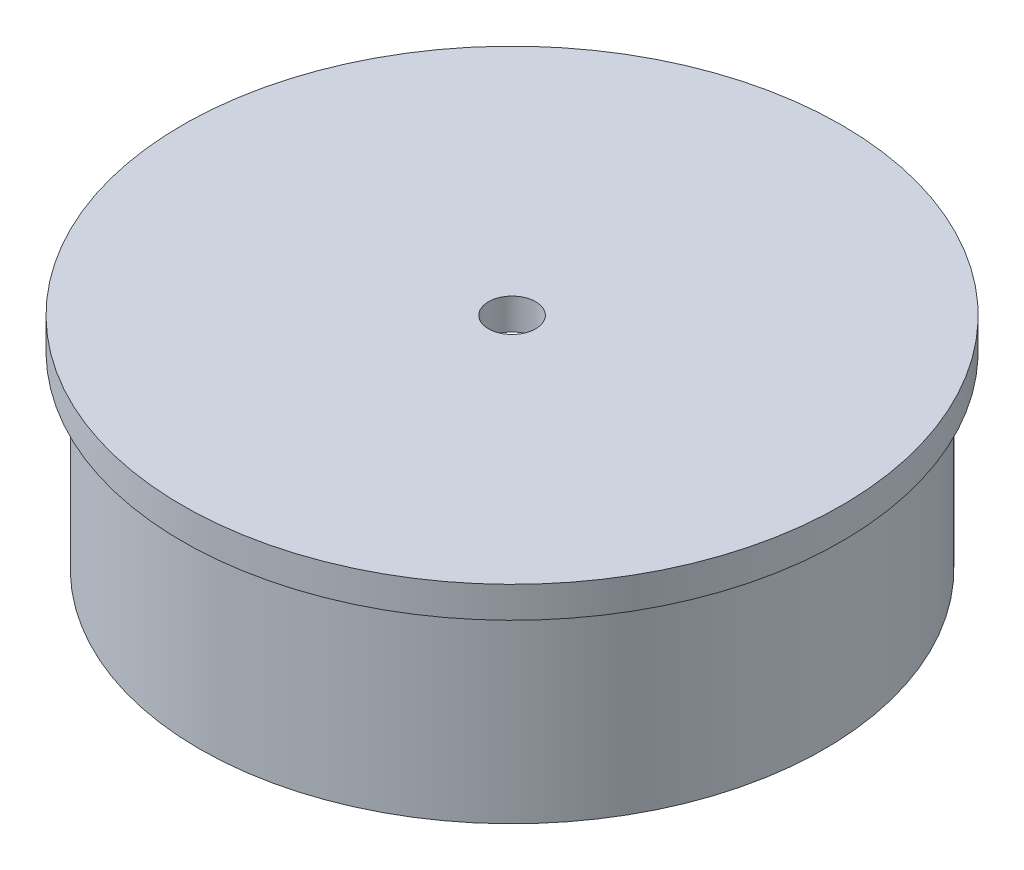
from build123d import *

# Parameters (mm, degrees)
SKETCH3_R = 2.38125
FILLET1_R = 1.27


with BuildPart() as part:
    # Sketch1 → Revolve1 (revolve)
    with BuildSketch(Plane.XY, mode=Mode.PRIVATE) as revolve1_sk:
        with BuildLine():
            Line((-21.0693, -14.8), (-21.0693, -2.1))
            Line((-21.0693, -2.1), (-22.225, -2.1))
            Line((-22.225, -2.1), (-22.225, 0))
            Line((-22.225, 0), (-1.5875, 0))
            Line((-1.5875, 0), (-1.5875, -2.1))
            Line((-1.5875, -2.1), (-17.4879, -2.1))
            ThreePointArc((-17.4879, -2.1), (-19.283951224, -2.843948776), (-20.0279, -4.64))
            Line((-20.0279, -4.64), (-20.0279, -14.8))
            Line((-20.0279, -14.8), (-21.0693, -14.8))
        make_face()
    revolve(revolve1_sk.sketch.rotate(Axis((0, 0, 0), (0, 1, 0)), 270), axis=Axis((0, 0, 0), (0, 1, 0)))

    # Sweep1: sweep along a path in Sketch2
    with BuildLine(Plane.XY.offset(-9.525)) as sweep1_path:
        Line((-1.5875, -2.1), (-1.5875, -4.555166767))
        ThreePointArc((-1.5875, -4.555166767), (0, -6.142666767), (1.5875, -4.555166767))
        Line((1.5875, -4.555166767), (1.5875, -2.1))
    # Sketch3 → Sweep1 (sweep)
    with BuildSketch(Plane.XZ.offset(2.1)):
        with Locations((4.702681807, -9.525)):
            Circle(SKETCH3_R)
    sweep1 = sweep(path=sweep1_path.line)

    # Fillet1
    fillet1_edges = [part.edges().sort_by_distance(p)[0] for p in [
        (2.321431807, -2.1, -9.525),
        (-2.321431807, -2.1, -9.525),
    ]]
    fillet(fillet1_edges, radius=FILLET1_R)

    # Mirror1: Sweep1 across plane
    add(sweep1.mirror(Plane.XY))


solid = part.part
